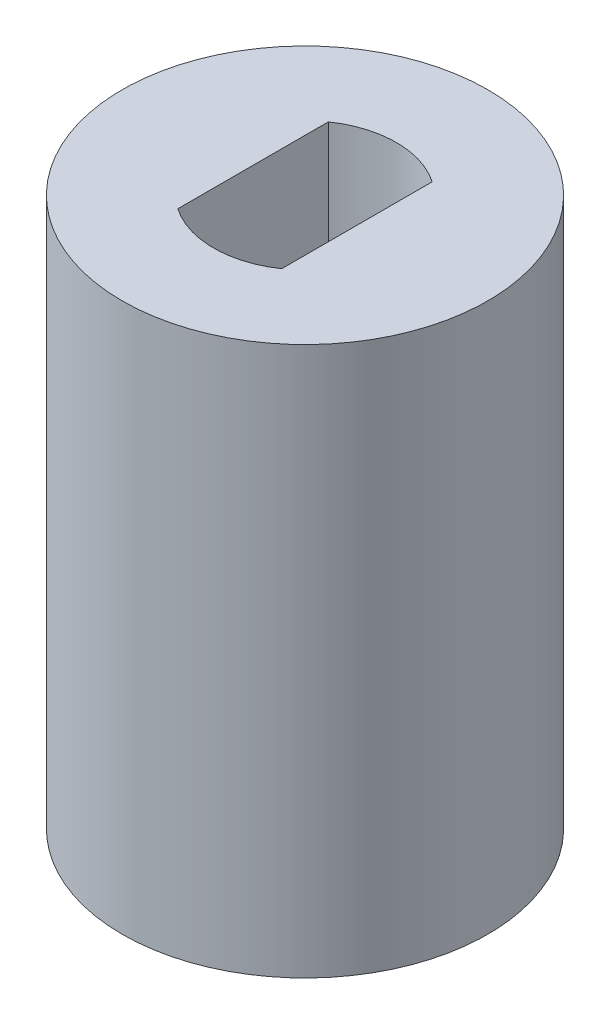
from build123d import *

# Parameters (mm, degrees)
SKETCH1_R           = 5
BOSS_EXTRUDE1_DEPTH = 15


with BuildPart() as part:
    # Sketch1 → Boss-Extrude1 (new body)
    with BuildSketch(Plane(origin=(0, 0, 0), x_dir=(1, 0, 0), z_dir=(0, 1, 0))):
        Circle(SKETCH1_R)
        with BuildLine():
            Line((-1.42, 2.057571384), (-1.42, -2.057571384))
            ThreePointArc((-1.42, -2.057571384), (0, -2.5), (1.42, -2.057571384))
            Line((1.42, -2.057571384), (1.42, 2.057571384))
            ThreePointArc((1.42, 2.057571384), (0, 2.5), (-1.42, 2.057571384))
        make_face(mode=Mode.SUBTRACT)
    extrude(amount=BOSS_EXTRUDE1_DEPTH)


solid = part.part
